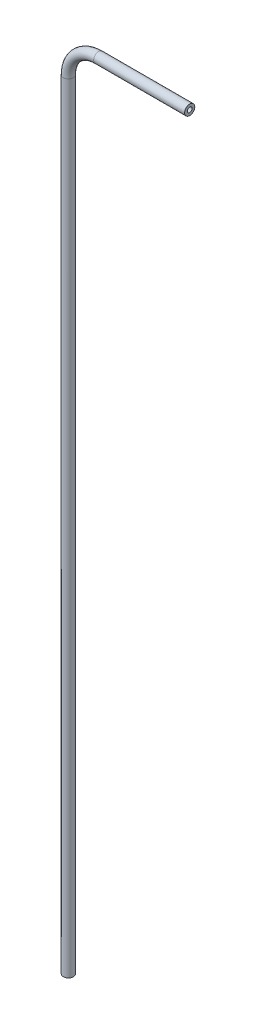
from build123d import *

# Parameters (mm, degrees)
SKETCH2_R   = 3.175
SKETCH2_R_2 = 1.524


with BuildPart() as part:
    # Sweep1: sweep along a path in Sketch1
    with BuildLine(Plane.XY) as sweep1_path:
        Line((0, -490.472317881), (0, -1.522317881))
        ThreePointArc((0, -1.522317881), (5.579615818, 11.948066301), (19.05, 17.527682119))
        Line((19.05, 17.527682119), (76.2, 17.527682119))
    # Sketch2 → Sweep1 (sweep)
    with BuildSketch(Plane(origin=(76.2, 17.527682119, 0), x_dir=(0, 0, -1), z_dir=(1, 0, 0))):
        Circle(SKETCH2_R)
        Circle(SKETCH2_R_2, mode=Mode.SUBTRACT)
    sweep(path=sweep1_path.line)


solid = part.part
